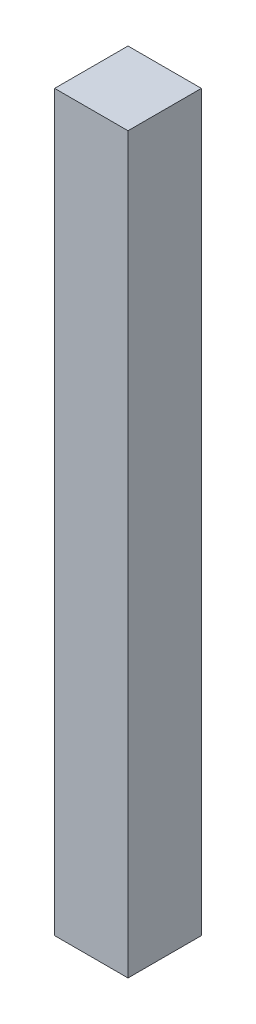
from build123d import *

# Parameters (mm, degrees)
ESBO_O2_W                = 50
ESBO_O2_H                = 50
RESSALTO_EXTRUS_O1_DEPTH = 500


with BuildPart() as part:
    # Esboço2 → Ressalto-extrusão1 (new body)
    with BuildSketch(Plane(origin=(0, 0, 0), x_dir=(1, 0, 0), z_dir=(0, 1, 0))):
        with Locations((-25, 4.076086957)):
            Rectangle(ESBO_O2_W, ESBO_O2_H)
    extrude(amount=RESSALTO_EXTRUS_O1_DEPTH)


solid = part.part
